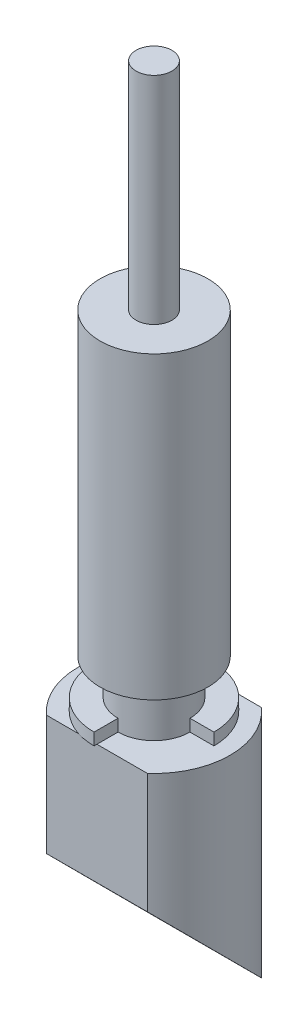
from build123d import *

# Parameters (mm, degrees)
SKETCH1_R           = 4.5
BOSS_EXTRUDE1_DEPTH = 25
SKETCH2_R           = 3
BOSS_EXTRUDE2_DEPTH = 4
BOSS_EXTRUDE3_DEPTH = 1
SKETCH4_R           = 6.35
BOSS_EXTRUDE4_DEPTH = 19.54
CUT_EXTRUDE1_DEPTH  = 19.54
SKETCH7_R           = 1.5
BOSS_EXTRUDE5_DEPTH = 18


with BuildPart() as part:
    # Sketch1 → Boss-Extrude1 (new body)
    with BuildSketch(Plane(origin=(0, 0, 0), x_dir=(1, 0, 0), z_dir=(0, 1, 0))):
        Circle(SKETCH1_R)
    extrude(amount=BOSS_EXTRUDE1_DEPTH)

    # Sketch2 → Boss-Extrude2 (add)
    with BuildSketch(Plane.XZ):
        Circle(SKETCH2_R)
    extrude(amount=BOSS_EXTRUDE2_DEPTH)

    # Sketch3 → Boss-Extrude3 (add)
    with BuildSketch(Plane.XZ.offset(4)):
        with BuildLine():
            Line((0, 3), (0, 5))
            ThreePointArc((0, 5), (-3.535533906, -3.535533906), (5, 0))
            Line((5, 0), (3, 0))
            ThreePointArc((3, 0), (-2.121320344, -2.121320344), (0, 3))
        make_face()
    extrude(amount=-BOSS_EXTRUDE3_DEPTH)

    # Sketch4 → Boss-Extrude4 (add)
    with BuildSketch(Plane.XZ.offset(4)):
        Circle(SKETCH4_R)
    extrude(amount=BOSS_EXTRUDE4_DEPTH)

    # Sketch6 → Cut-Extrude1 (cut)
    with BuildSketch(Plane(origin=(6.35, 0, 0), x_dir=(0, 0, -1), z_dir=(1, 0, 0))):
        Polygon((-8.967576024, -4), (-4.76, -4), (-4.76, -14), (4.76, -23.54), (4.76, -4), (8.459767383, -4), (8.459767383, -27.476657102), (-8.967576024, -27.476657102), align=None)
    extrude(amount=-CUT_EXTRUDE1_DEPTH, mode=Mode.SUBTRACT)

    # Sketch7 → Boss-Extrude5 (add)
    with BuildSketch(Plane(origin=(0, 25, 0), x_dir=(1, 0, 0), z_dir=(0, 1, 0))):
        Circle(SKETCH7_R)
    extrude(amount=BOSS_EXTRUDE5_DEPTH)


solid = part.part
